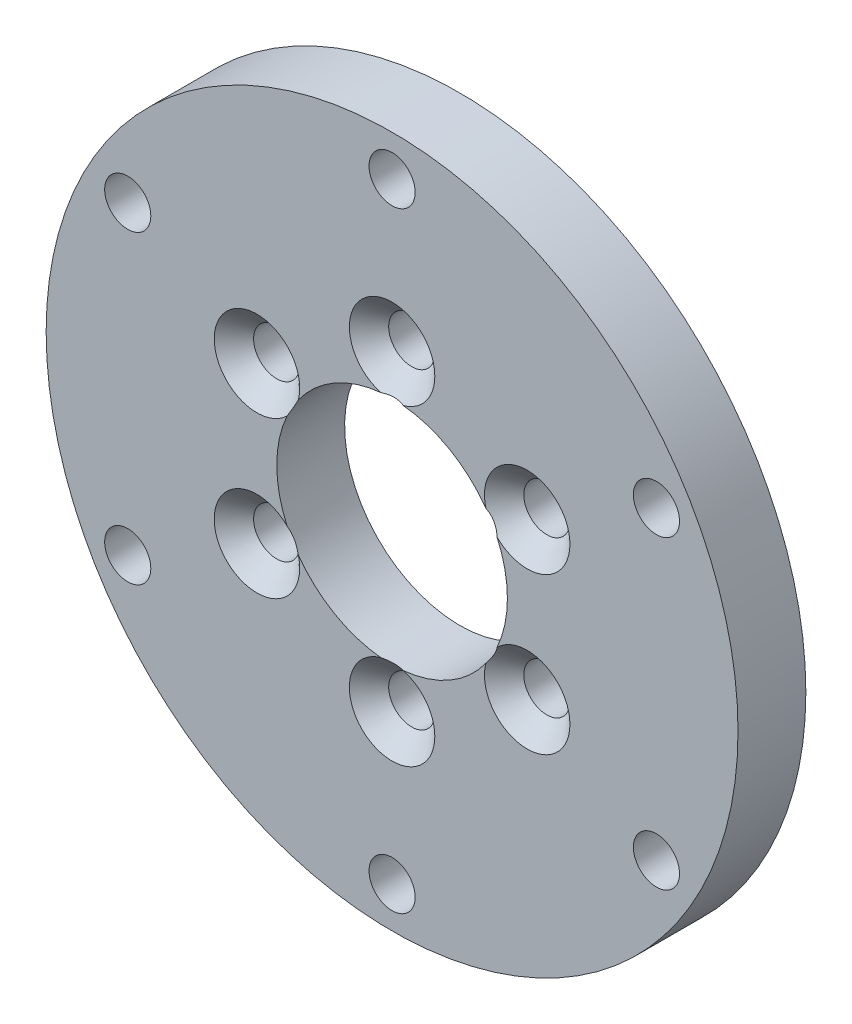
from build123d import *

# Parameters (mm, degrees)
SKETCH1_R           = 25.5
SKETCH1_R_2         = 8.5
BOSS_EXTRUDE1_DEPTH = 5
CIRPATTERN1_COUNT   = 6


with BuildPart() as part:
    # Sketch1 → Boss-Extrude1 (new body)
    with BuildSketch(Plane.XY):
        Circle(SKETCH1_R)
        Circle(SKETCH1_R_2, mode=Mode.SUBTRACT)
    extrude(amount=BOSS_EXTRUDE1_DEPTH)

    # Sketch3 → M3 Clearance Hole1 (revolve, cut)
    with BuildSketch(Plane(origin=(0, 22.5, 5), x_dir=(0, -1, 0), z_dir=(1, 0, 0))):
        Polygon((0, 0), (0, 11.021463052), (1.7, 10), (1.7, 0), align=None)
    m3_clearance_hole1 = revolve(axis=Axis((0, 22.5, 11.35), (0, 0, -1)), mode=Mode.SUBTRACT)

    # Sketch5 → CSK for M3 Countersunk Flat Head Screw3 (revolve, cut)
    with BuildSketch(Plane(origin=(0, 11.5, 5), x_dir=(0, -1, 0), z_dir=(1, 0, 0))):
        Polygon((0, 0), (0, 11.021463052), (1.7, 10), (1.7, 1.45), (3.15, 0), align=None)
    csk_for_m3_countersunk_flat_head_screw3 = revolve(axis=Axis((0, 11.5, 11.35), (0, 0, -1)), mode=Mode.SUBTRACT)

    # CirPattern1: M3 Clearance Hole1, CSK for M3 Countersunk Flat Head Screw3 ×6 about axis
    cirpattern1_axis = Axis((0, 0, 0), (0, 0, 1))
    for i in range(1, CIRPATTERN1_COUNT):
        add(m3_clearance_hole1.rotate(cirpattern1_axis, i * 360 / CIRPATTERN1_COUNT), mode=Mode.SUBTRACT)
        add(csk_for_m3_countersunk_flat_head_screw3.rotate(cirpattern1_axis, i * 360 / CIRPATTERN1_COUNT), mode=Mode.SUBTRACT)


solid = part.part
